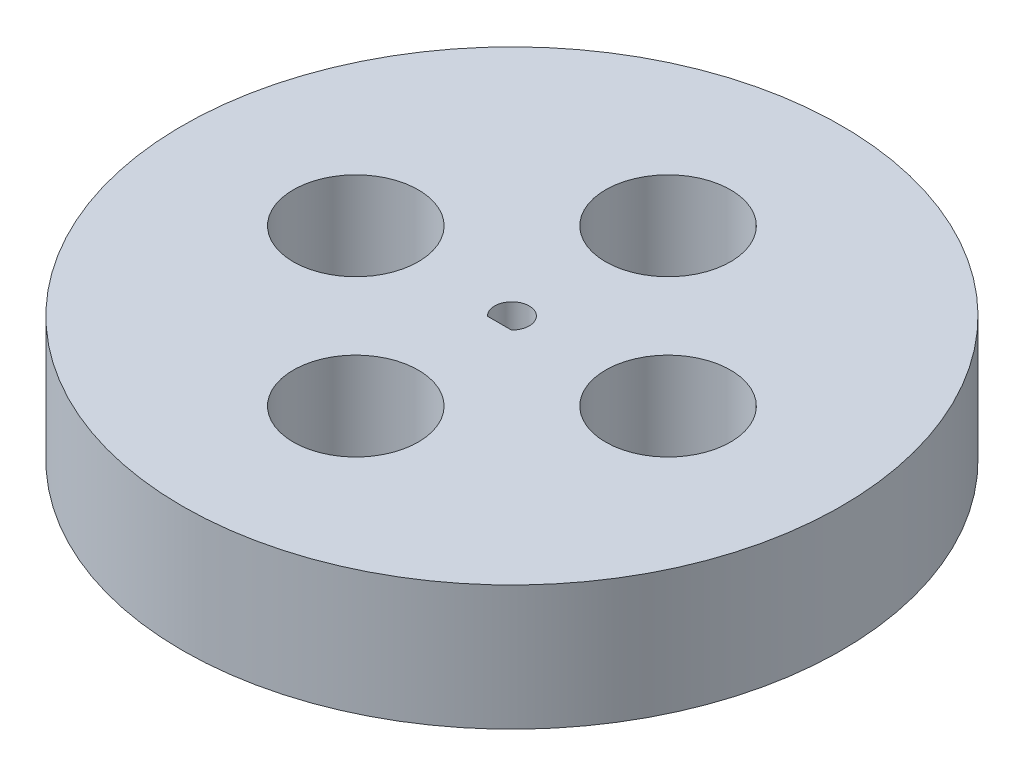
from build123d import *

# Parameters (mm, degrees)
SKETCH1_R           = 52.771281292
BOSS_EXTRUDE1_DEPTH = 20
SKETCH3_R           = 10
CUT_EXTRUDE1_DEPTH  = 20


with BuildPart() as part:
    # Sketch1 → Boss-Extrude1 (new body)
    with BuildSketch(Plane(origin=(0, 0, 0), x_dir=(1, 0, 0), z_dir=(0, 1, 0))):
        Circle(SKETCH1_R)
        with BuildLine():
            Line((-1.918332609, -2), (1.918332609, -2))
            ThreePointArc((1.918332609, -2), (0, 2.771281292), (-1.918332609, -2))
        make_face(mode=Mode.SUBTRACT)
    extrude(amount=BOSS_EXTRUDE1_DEPTH)

    # Sketch3 → Cut-Extrude1 (cut)
    with BuildSketch(Plane(origin=(0, 20, 0), x_dir=(1, 0, 0), z_dir=(0, 1, 0))):
        with Locations((-25, 0)):
            Circle(SKETCH3_R)
        with Locations((0, 25)):
            Circle(SKETCH3_R)
        with Locations((25, 0)):
            Circle(SKETCH3_R)
        with Locations((0, -25)):
            Circle(SKETCH3_R)
    extrude(amount=-CUT_EXTRUDE1_DEPTH, mode=Mode.SUBTRACT)


solid = part.part
